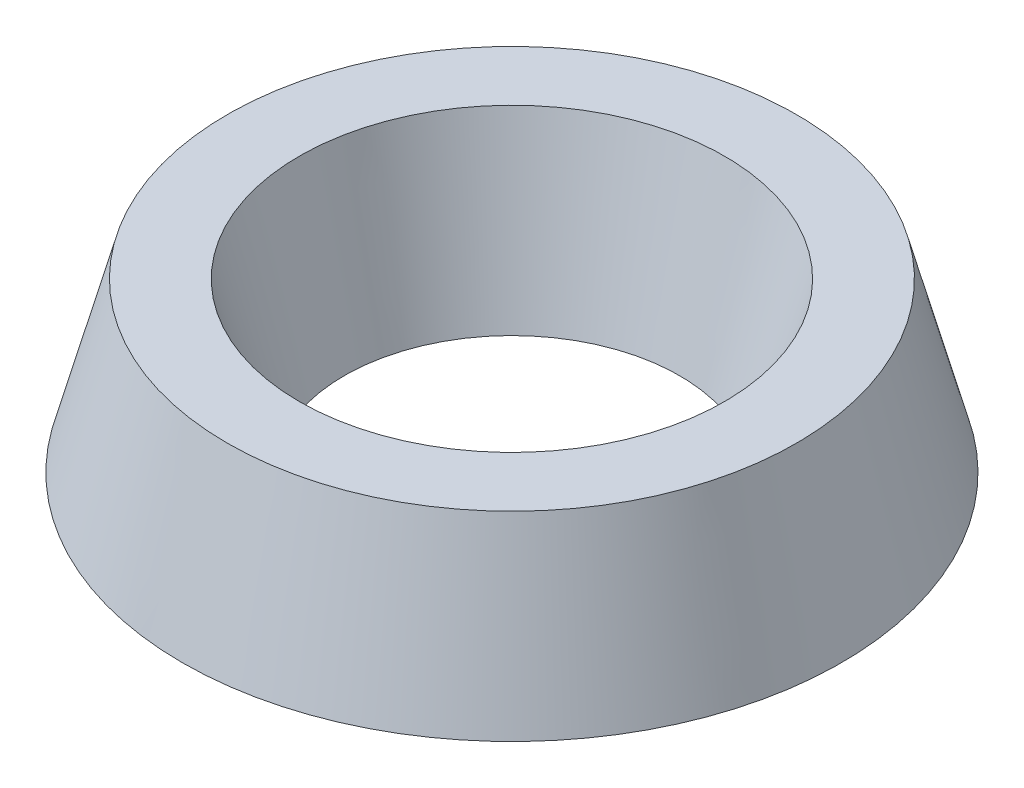
from build123d import *

# Parameters (mm, degrees)
SKETCH1_R           = 5.896069208
SKETCH1_R_2         = 3
BOSS_EXTRUDE1_DEPTH = 3
BOSS_EXTRUDE1_TAPER = 15


with BuildPart() as part:
    # Sketch1 → Boss-Extrude1 (new body)
    with BuildSketch(Plane(origin=(0, 0, 0), x_dir=(1, 0, 0), z_dir=(0, 1, 0))):
        Circle(SKETCH1_R)
        Circle(SKETCH1_R_2, mode=Mode.SUBTRACT)
    extrude(amount=BOSS_EXTRUDE1_DEPTH, taper=BOSS_EXTRUDE1_TAPER)


solid = part.part
